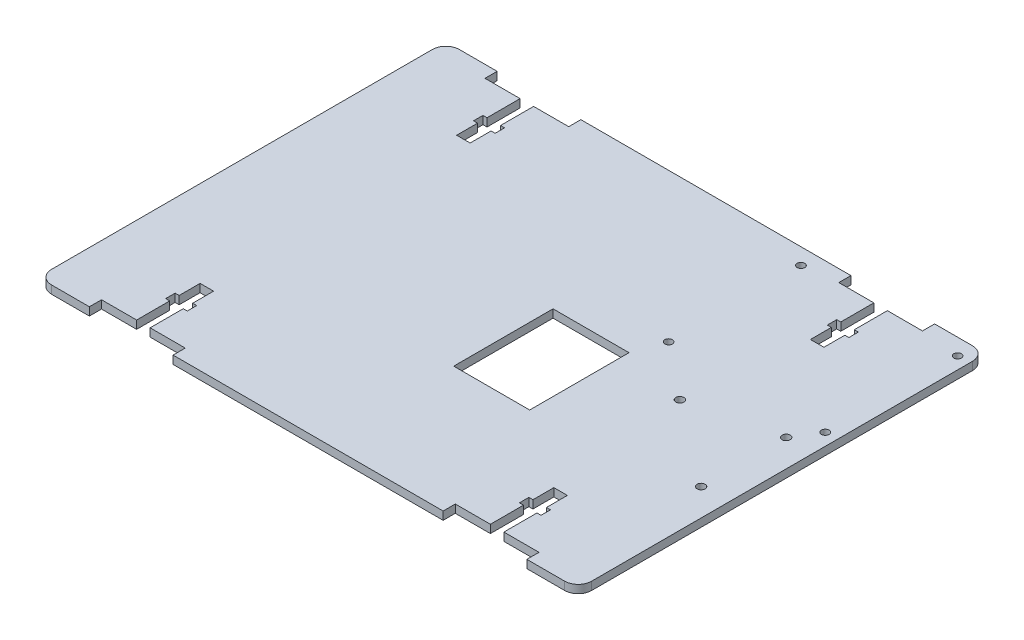
from build123d import *

# Parameters (mm, degrees)
SKETCH1_W           = 200
SKETCH1_H           = 151
BOSS_EXTRUDE1_DEPTH = 3
SKETCH2_W           = 28.1297743
SKETCH2_H           = 36.772110208
SKETCH2_R           = 1.5
SKETCH2_R_2         = 1.4
CUT_EXTRUDE2_DEPTH  = 4
FILLET1_R           = 5


with BuildPart() as part:
    # Sketch1 → Boss-Extrude1 (new body)
    with BuildSketch(Plane(origin=(0, 0, 0), x_dir=(1, 0, 0), z_dir=(0, 1, 0))):
        Rectangle(SKETCH1_W, SKETCH1_H)
    extrude(amount=BOSS_EXTRUDE1_DEPTH)

    # Sketch2 → Cut-Extrude2 (cut, through all)
    with BuildSketch(Plane(origin=(0, 3, 0), x_dir=(1, 0, 0), z_dir=(0, 1, 0))):
        Polygon((-50, 75.5), (-81, 75.5), (-81, 71), (-68, 71), (-68, 58.75), (-69.5, 58.75), (-69.5, 55.25), (-68, 55.25), (-68, 47.5), (-63, 47.5), (-63, 55.25), (-61.5, 55.25), (-61.5, 58.75), (-63, 58.75), (-63, 71), (-50, 71), align=None)
        Polygon((50, 71), (63, 71), (63, 58.75), (61.5, 58.75), (61.5, 55.25), (63, 55.25), (63, 47.5), (68, 47.5), (68, 55.25), (69.5, 55.25), (69.5, 58.75), (68, 58.75), (68, 71), (81, 71), (81, 75.5), (50, 75.5), align=None)
        Polygon((50, -75.5), (81, -75.5), (81, -71), (68, -71), (68, -58.75), (69.5, -58.75), (69.5, -55.25), (68, -55.25), (68, -47.5), (63, -47.5), (63, -55.25), (61.5, -55.25), (61.5, -58.75), (63, -58.75), (63, -71), (50, -71), align=None)
        Polygon((-50, -71), (-63, -71), (-63, -58.75), (-61.5, -58.75), (-61.5, -55.25), (-63, -55.25), (-63, -47.5), (-68, -47.5), (-68, -55.25), (-69.5, -55.25), (-69.5, -58.75), (-68, -58.75), (-68, -71), (-81, -71), (-81, -75.5), (-50, -75.5), align=None)
        with Locations((19.572588651, -8.701882989)):
            Rectangle(SKETCH2_W, SKETCH2_H)
        with Locations((89.92, -19.9)):
            Circle(SKETCH2_R)
        with Locations((89.92, 11.61)):
            Circle(SKETCH2_R)
        with Locations((58.16, 4)):
            Circle(SKETCH2_R)
        with Locations((95.5, 20.5)):
            Circle(SKETCH2_R_2)
        with Locations((37.5, 20.5)):
            Circle(SKETCH2_R_2)
        with Locations((37.5, 69.5)):
            Circle(SKETCH2_R_2)
        with Locations((95.5, 69.5)):
            Circle(SKETCH2_R_2)
    extrude(amount=-CUT_EXTRUDE2_DEPTH, mode=Mode.SUBTRACT)

    # Fillet1
    fillet1_edges = [part.edges().sort_by_distance(p)[0] for p in [
        (100, 1.5, 75.5),
        (-100, 1.5, 75.5),
        (-100, 1.5, -75.5),
        (100, 1.5, -75.5),
    ]]
    fillet(fillet1_edges, radius=FILLET1_R)


solid = part.part
